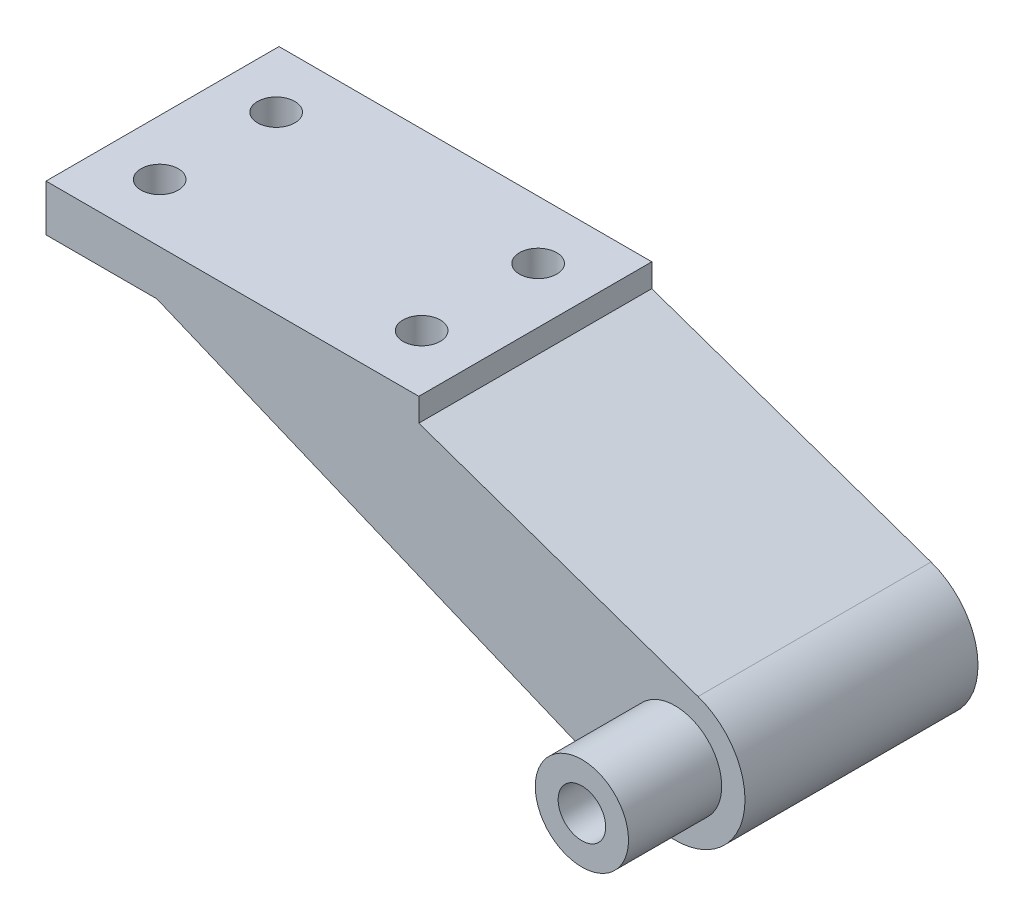
from build123d import *

# Parameters (mm, degrees)
SKETCH1_W           = 50.8
SKETCH1_H           = 31.75
BOSS_EXTRUDE1_DEPTH = 6.35
SKETCH2_R           = 9.525
SKETCH2_R_2         = 3.2385
BOSS_EXTRUDE2_DEPTH = 31.75
BOSS_EXTRUDE3_DEPTH = 31.75
SKETCH4_R           = 6.35
SKETCH4_R_2         = 3.2385
BOSS_EXTRUDE4_DEPTH = 12.7
CUT_EXTRUDE1_REACH  = 8.35
SKETCH5_R           = 2.54
SKETCH6_R           = 2.54
CUT_EXTRUDE2_DEPTH  = 35.925
SKETCH7_R           = 4.7625
CUT_EXTRUDE3_DEPTH  = 19.05


with BuildPart() as part:
    # Sketch1 → Boss-Extrude1 (new body)
    with BuildSketch(Plane(origin=(0, 0, 0), x_dir=(1, 0, 0), z_dir=(0, 1, 0))):
        with Locations((25.4, 15.875)):
            Rectangle(SKETCH1_W, SKETCH1_H)
    extrude(amount=BOSS_EXTRUDE1_DEPTH)



with BuildPart() as body_2:
    # Sketch2 → Boss-Extrude2 (new body)
    with BuildSketch(Plane.XY):
        with Locations((85.725, -19.05)):
            Circle(SKETCH2_R)
        with Locations((85.725, -19.05)):
            Circle(SKETCH2_R_2, mode=Mode.SUBTRACT)
    extrude(amount=-BOSS_EXTRUDE2_DEPTH)


with BuildPart() as part_1:
    add(part.part)

    add(body_2.part)  # Boss-Extrude3 merges body 2
    # Sketch3 → Boss-Extrude3 (add)
    with BuildSketch(Plane.XY):
        with BuildLine():
            Line((50.8, 3.175), (88.852564162, -10.05311346))
            ThreePointArc((88.852564162, -10.05311346), (76.82515217, -15.656132943), (82.067835176, -27.844928678))
            Line((82.067835176, -27.844928678), (15.104990042, 0))
            Line((15.104990042, 0), (15.104990042, 3.175))
            Line((15.104990042, 3.175), (50.8, 3.175))
        make_face()
    extrude(amount=-BOSS_EXTRUDE3_DEPTH)

    # Sketch4 → Boss-Extrude4 (add)
    with BuildSketch(Plane.XY):
        with Locations((85.725, -19.05)):
            Circle(SKETCH4_R)
        with Locations((85.725, -19.05)):
            Circle(SKETCH4_R_2, mode=Mode.SUBTRACT)
    extrude(amount=BOSS_EXTRUDE4_DEPTH)

    # Sketch5 → Cut-Extrude1 (cut, up to next)
    with BuildSketch(Plane.XZ, mode=Mode.PRIVATE) as cut_extrude1_sk1:
        with Locations((7.552495021, -7.9375)):
            Circle(SKETCH5_R)
    cut_extrude1_tool1 = extrude(cut_extrude1_sk1.sketch, amount=-CUT_EXTRUDE1_REACH, mode=Mode.PRIVATE) & part_1.part
    add(cut_extrude1_tool1.solids().sort_by_distance((7.552495, 0, -7.9375))[0], mode=Mode.SUBTRACT)
    # Sketch5 → Cut-Extrude1 (cut, up to next)
    with BuildSketch(Plane.XZ, mode=Mode.PRIVATE) as cut_extrude1_sk2:
        with Locations((7.552495021, -23.8125)):
            Circle(SKETCH5_R)
    cut_extrude1_tool2 = extrude(cut_extrude1_sk2.sketch, amount=-CUT_EXTRUDE1_REACH, mode=Mode.PRIVATE) & part_1.part
    add(cut_extrude1_tool2.solids().sort_by_distance((7.552495, 0, -23.8125))[0], mode=Mode.SUBTRACT)

    # Sketch6 → Cut-Extrude2 (cut, through all)
    with BuildSketch(Plane(origin=(0, 6.35, 0), x_dir=(1, 0, 0), z_dir=(0, 1, 0))):
        with Locations((43.247504979, 7.9375)):
            Circle(SKETCH6_R)
        with Locations((43.247504979, 23.8125)):
            Circle(SKETCH6_R)
    extrude(amount=-CUT_EXTRUDE2_DEPTH, mode=Mode.SUBTRACT)

    # Sketch7 → Cut-Extrude3 (cut)
    with BuildSketch(Plane(origin=(0, -19.05, 0), x_dir=(1, 0, 0), z_dir=(0, 1, 0))):
        with Locations((43.247504979, 23.8125)):
            Circle(SKETCH7_R)
        with Locations((43.247504979, 7.9375)):
            Circle(SKETCH7_R)
    extrude(amount=CUT_EXTRUDE3_DEPTH, mode=Mode.SUBTRACT)


solid = part_1.part
